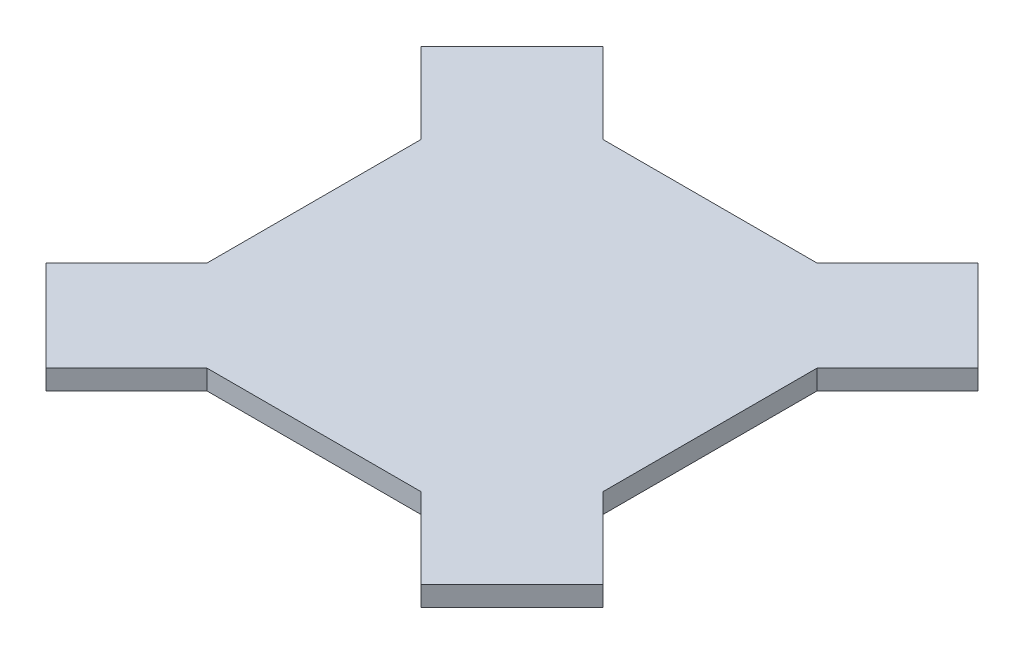
from build123d import *

# Parameters (mm, degrees)
SKETCH1_W           = 80
SKETCH1_H           = 80
BOSS_EXTRUDE1_DEPTH = 4
BOSS_EXTRUDE2_DEPTH = 4


with BuildPart() as part:
    # Sketch1 → Boss-Extrude1 (new body)
    with BuildSketch(Plane(origin=(0, 0, 0), x_dir=(1, 0, 0), z_dir=(0, 1, 0))):
        Rectangle(SKETCH1_W, SKETCH1_H)
    extrude(amount=BOSS_EXTRUDE1_DEPTH)

    # Sketch2 → Boss-Extrude2 (add)
    with BuildSketch(Plane(origin=(0, 4, 0), x_dir=(1, 0, 0), z_dir=(0, 1, 0))):
        Polygon((-56.263455967, 37.878679656), (-40, 21.615223689), (-40, 40), (-21.615223689, 40), (-37.878679656, 56.263455967), align=None)
        Polygon((-37.878679656, -56.263455967), (-21.615223689, -40), (-40, -40), (-40, -21.615223689), (-56.263455967, -37.878679656), align=None)
        Polygon((40, 40), (40, 21.615223689), (56.263455967, 37.878679656), (37.878679656, 56.263455967), (21.615223689, 40), align=None)
        Polygon((21.615223689, -40), (37.878679656, -56.263455967), (56.263455967, -37.878679656), (40, -21.615223689), (40, -40), align=None)
    extrude(amount=-BOSS_EXTRUDE2_DEPTH)


solid = part.part
